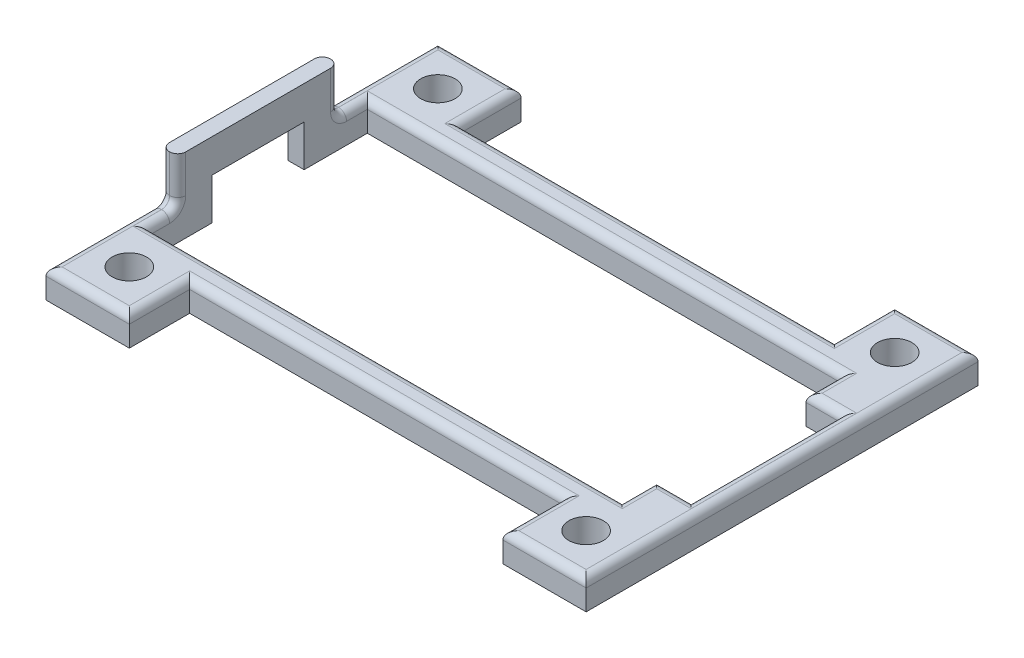
from build123d import *

# Parameters (mm, degrees)
SKETCH1_W           = 47
SKETCH1_H           = 23.6
SKETCH1_W_2         = 44.18
SKETCH1_H_2         = 19
BOSS_EXTRUDE1_DEPTH = 5.5
SKETCH3_W           = 44.18
SKETCH3_H           = 19
BOSS_EXTRUDE2_DEPTH = 3
SKETCH6_W           = 7.25
SKETCH6_H           = 5.5
BOSS_EXTRUDE3_DEPTH = 5.25
SKETCH7_W           = 7.25
SKETCH7_H           = 5.5
BOSS_EXTRUDE4_DEPTH = 5.25
SKETCH8_R           = 1.5
CUT_EXTRUDE2_DEPTH  = 6.5
SKETCH9_W           = 51.734881385
SKETCH9_H           = 36.74917656
CUT_EXTRUDE3_DEPTH  = 3
SKETCH10_W          = 1.41
SKETCH10_H          = 14
BOSS_EXTRUDE5_DEPTH = 4
SKETCH11_W          = 3
SKETCH11_H          = 2.5
BOSS_EXTRUDE6_DEPTH = 3
SKETCH12_W          = 1.41
SKETCH12_H          = 8
CUT_EXTRUDE4_DEPTH  = 3.6
FILLET1_R           = 0.7


with BuildPart() as part:
    # Sketch1 → Boss-Extrude1 (new body)
    with BuildSketch(Plane(origin=(0, 0, 0), x_dir=(1, 0, 0), z_dir=(0, 1, 0))):
        with Locations((22.09, 9.5)):
            Rectangle(SKETCH1_W, SKETCH1_H)
        with Locations((22.09, 9.5)):
            Rectangle(SKETCH1_W_2, SKETCH1_H_2, mode=Mode.SUBTRACT)
    extrude(amount=BOSS_EXTRUDE1_DEPTH)

    # Sketch3 → Boss-Extrude2 (add)
    with BuildSketch(Plane.XZ):
        with Locations((22.09, -9.5)):
            Rectangle(SKETCH3_W, SKETCH3_H)
    extrude(amount=-BOSS_EXTRUDE2_DEPTH)

    # Sketch6 → Boss-Extrude3 (add)
    with BuildSketch(Plane.XY.offset(2.3)):
        with Locations((2.215, 2.75)):
            Rectangle(SKETCH6_W, SKETCH6_H)
        with Locations((41.965, 2.75)):
            Rectangle(SKETCH6_W, SKETCH6_H)
    extrude(amount=BOSS_EXTRUDE3_DEPTH)

    # Sketch7 → Boss-Extrude4 (add)
    with BuildSketch(Plane(origin=(0, 0, -21.3), x_dir=(-1, 0, 0), z_dir=(0, 0, -1))):
        with Locations((-41.965, 2.75)):
            Rectangle(SKETCH7_W, SKETCH7_H)
        with Locations((-2.215, 2.75)):
            Rectangle(SKETCH7_W, SKETCH7_H)
    extrude(amount=BOSS_EXTRUDE4_DEPTH)

    # Sketch8 → Cut-Extrude2 (cut, through all)
    with BuildSketch(Plane(origin=(0, 5.5, 0), x_dir=(1, 0, 0), z_dir=(0, 1, 0))):
        with Locations((41.965, 22.925)):
            Circle(SKETCH8_R)
        with Locations((41.965, -3.925)):
            Circle(SKETCH8_R)
        with Locations((2.215, -3.925)):
            Circle(SKETCH8_R)
        with Locations((2.215, 22.925)):
            Circle(SKETCH8_R)
    extrude(amount=-CUT_EXTRUDE2_DEPTH, mode=Mode.SUBTRACT)

    # Sketch9 → Cut-Extrude3 (cut)
    with BuildSketch(Plane.XZ):
        with Locations((23.178173587, -9.700906739)):
            Rectangle(SKETCH9_W, SKETCH9_H)
    extrude(amount=-CUT_EXTRUDE3_DEPTH, mode=Mode.SUBTRACT)

    # Sketch10 → Boss-Extrude5 (add)
    with BuildSketch(Plane(origin=(0, 5.5, 0), x_dir=(1, 0, 0), z_dir=(0, 1, 0))):
        with Locations((-0.705, 9.5)):
            Rectangle(SKETCH10_W, SKETCH10_H)
    extrude(amount=BOSS_EXTRUDE5_DEPTH)

    # Sketch11 → Boss-Extrude6 (add)
    with BuildSketch(Plane.ZY.offset(-44.18)):
        with Locations((-17.5, 4.25)):
            Rectangle(SKETCH11_W, SKETCH11_H)
        with Locations((-1.5, 4.25)):
            Rectangle(SKETCH11_W, SKETCH11_H)
    extrude(amount=BOSS_EXTRUDE6_DEPTH)

    # Sketch12 → Cut-Extrude4 (cut)
    with BuildSketch(Plane.XZ.offset(-3)):
        with Locations((-0.705, -9.5)):
            Rectangle(SKETCH12_W, SKETCH12_H)
    extrude(amount=-CUT_EXTRUDE4_DEPTH, mode=Mode.SUBTRACT)

    # Fillet1
    fillet1_edges = [part.edges().sort_by_distance(p)[0] for p in [
        (45.59, 5.5, -9.5),
        (0, 5.5, -17.75),
        (-1.41, 5.5, 2.525),
        (0, 5.5, -1.25),
        (20.59, 5.5, 0),
        (-1.41, 7.5, -16.5),
        (-0.705, 5.5, -2.5),
        (-1.41, 7.5, -2.5),
        (0, 7.5, -2.5),
        (-0.705, 5.5, -16.5),
        (0, 7.5, -16.5),
        (20.59, 5.5, -19),
        (42.68, 5.5, -16),
        (41.18, 5.5, -17.5),
        (44.18, 5.5, -9.5),
        (42.68, 5.5, -3),
        (41.18, 5.5, -1.5),
        (-1.41, 5.5, -21.525),
        (22.09, 5.5, 2.3),
        (5.84, 5.5, 4.925),
        (2.215, 5.5, 7.55),
        (38.34, 5.5, 4.925),
        (41.965, 5.5, 7.55),
        (22.09, 5.5, -21.3),
        (38.34, 5.5, -23.925),
        (41.965, 5.5, -26.55),
        (5.84, 5.5, -23.925),
        (2.215, 5.5, -26.55),
    ]]
    fillet(fillet1_edges, radius=FILLET1_R)


solid = part.part
